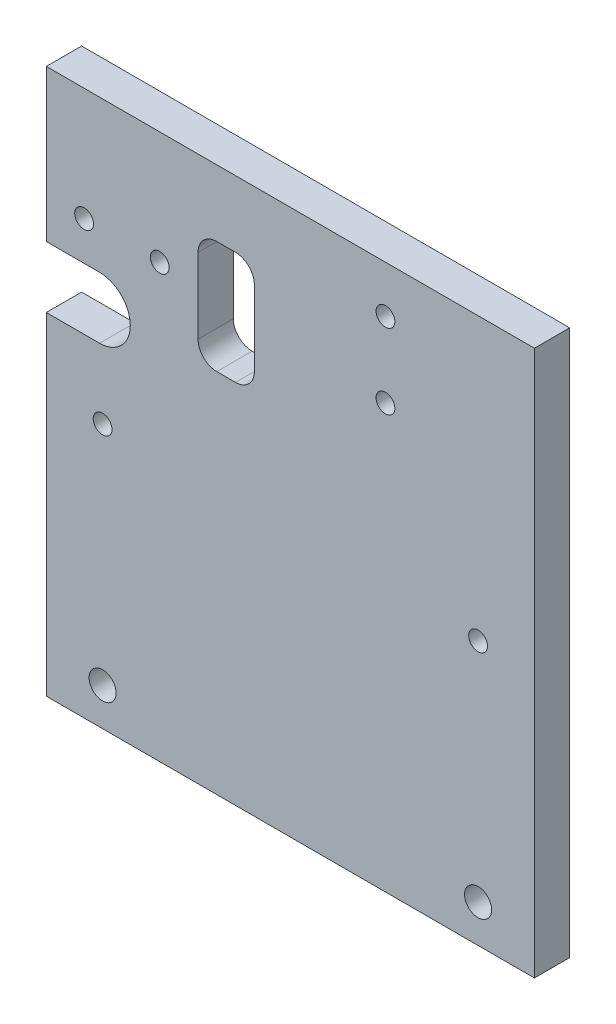
from build123d import *

# Parameters (mm, degrees)
SKETCH1_W           = 130
SKETCH1_H           = 145.26
SKETCH1_R           = 3.6
SKETCH1_R_2         = 2.5
BOSS_EXTRUDE1_DEPTH = 9.4
SKETCH2_R           = 2.5
CUT_EXTRUDE1_DEPTH  = 10.4
CUT_EXTRUDE2_DEPTH  = 10.4
CUT_EXTRUDE3_DEPTH  = 10.4
SKETCH5_R           = 2.5
CUT_EXTRUDE4_DEPTH  = 10.4


with BuildPart() as part:
    # Sketch1 → Boss-Extrude1 (new body)
    with BuildSketch(Plane.XY):
        with Locations((50, 62.63)):
            Rectangle(SKETCH1_W, SKETCH1_H)
        Circle(SKETCH1_R, mode=Mode.SUBTRACT)
        with Locations((0, 60.26)):
            Circle(SKETCH1_R_2, mode=Mode.SUBTRACT)
        with Locations((100, 60.26)):
            Circle(SKETCH1_R_2, mode=Mode.SUBTRACT)
        with Locations((100, 0)):
            Circle(SKETCH1_R, mode=Mode.SUBTRACT)
    extrude(amount=BOSS_EXTRUDE1_DEPTH)

    # Sketch2 → Cut-Extrude1 (cut, through all)
    with BuildSketch(Plane.XY.offset(9.4)):
        with Locations((75.33, 122.766411568)):
            Circle(SKETCH2_R)
        with Locations((75.33, 102.766411568)):
            Circle(SKETCH2_R)
    extrude(amount=-CUT_EXTRUDE1_DEPTH, mode=Mode.SUBTRACT)

    # Sketch3 → Cut-Extrude2 (cut, through all)
    with BuildSketch(Plane(origin=(0, 0, 0), x_dir=(-1, 0, 0), z_dir=(0, 0, -1))):
        with BuildLine():
            Line((-35.40754614, 117.570367495), (-30.40754614, 117.570367495))
            ThreePointArc((-30.40754614, 117.570367495), (-26.872012234, 116.105901401), (-25.40754614, 112.570367495))
            Line((-25.40754614, 112.570367495), (-25.40754614, 92.570367495))
            ThreePointArc((-25.40754614, 92.570367495), (-26.872012234, 89.034833589), (-30.40754614, 87.570367495))
            Line((-30.40754614, 87.570367495), (-35.40754614, 87.570367495))
            ThreePointArc((-35.40754614, 87.570367495), (-38.943080046, 89.034833589), (-40.40754614, 92.570367495))
            Line((-40.40754614, 92.570367495), (-40.40754614, 112.570367495))
            ThreePointArc((-40.40754614, 112.570367495), (-38.943080046, 116.105901401), (-35.40754614, 117.570367495))
        make_face()
    extrude(amount=-CUT_EXTRUDE2_DEPTH, mode=Mode.SUBTRACT)

    # Sketch4 → Cut-Extrude3 (cut, through all)
    with BuildSketch(Plane.XY.offset(9.4)):
        with BuildLine():
            Line((-15, 78.5), (-15, 94.86))
            Line((-15, 94.86), (-0.81, 94.86))
            ThreePointArc((-0.81, 94.86), (7.37, 86.68), (-0.81, 78.5))
            Line((-0.81, 78.5), (-15, 78.5))
        make_face()
    extrude(amount=-CUT_EXTRUDE3_DEPTH, mode=Mode.SUBTRACT)

    # Sketch5 → Cut-Extrude4 (cut, through all)
    with BuildSketch(Plane.XY.offset(9.4)):
        with Locations((-4.926856844, 105.186)):
            Circle(SKETCH5_R)
        with Locations((15.215343156, 105.186)):
            Circle(SKETCH5_R)
    extrude(amount=-CUT_EXTRUDE4_DEPTH, mode=Mode.SUBTRACT)


solid = part.part
